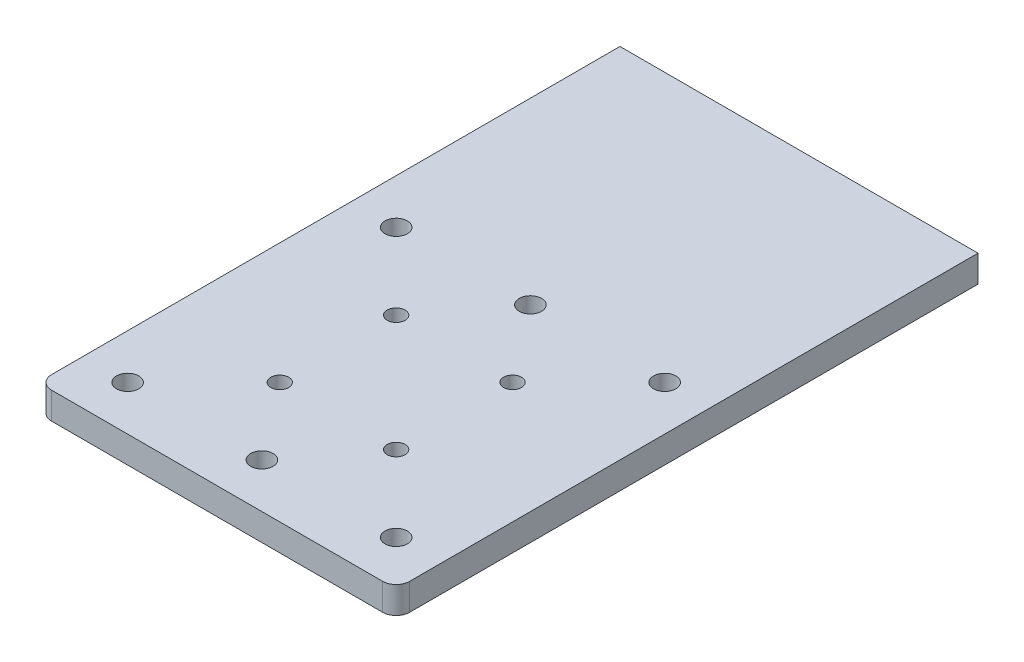
from build123d import *

# Parameters (mm, degrees)
SKETCH1_W           = 80
SKETCH1_H           = 130
SKETCH1_R           = 2
SKETCH1_R_2         = 2.5
BOSS_EXTRUDE1_DEPTH = 6
FILLET1_R           = 3


with BuildPart() as part:
    # Sketch1 → Boss-Extrude1 (new body)
    with BuildSketch(Plane(origin=(0, 0, 0), x_dir=(1, 0, 0), z_dir=(0, 1, 0))):
        with Locations((13, 38)):
            Rectangle(SKETCH1_W, SKETCH1_H)
        with Locations((0, 26)):
            Circle(SKETCH1_R, mode=Mode.SUBTRACT)
        with Locations((26, 26)):
            Circle(SKETCH1_R, mode=Mode.SUBTRACT)
        with Locations((26, 0)):
            Circle(SKETCH1_R, mode=Mode.SUBTRACT)
        Circle(SKETCH1_R, mode=Mode.SUBTRACT)
        with Locations((-17, 43)):
            Circle(SKETCH1_R_2, mode=Mode.SUBTRACT)
        with Locations((43, 43)):
            Circle(SKETCH1_R_2, mode=Mode.SUBTRACT)
        with Locations((43, -17)):
            Circle(SKETCH1_R_2, mode=Mode.SUBTRACT)
        with Locations((-17, -17)):
            Circle(SKETCH1_R_2, mode=Mode.SUBTRACT)
        with Locations((13, 43)):
            Circle(SKETCH1_R_2, mode=Mode.SUBTRACT)
        with Locations((13, -17)):
            Circle(SKETCH1_R_2, mode=Mode.SUBTRACT)
    extrude(amount=BOSS_EXTRUDE1_DEPTH)

    # Fillet1
    fillet1_edges = [part.edges().sort_by_distance(p)[0] for p in [
        (53, 3, 27),
        (-27, 3, 27),
    ]]
    fillet(fillet1_edges, radius=FILLET1_R)


solid = part.part
